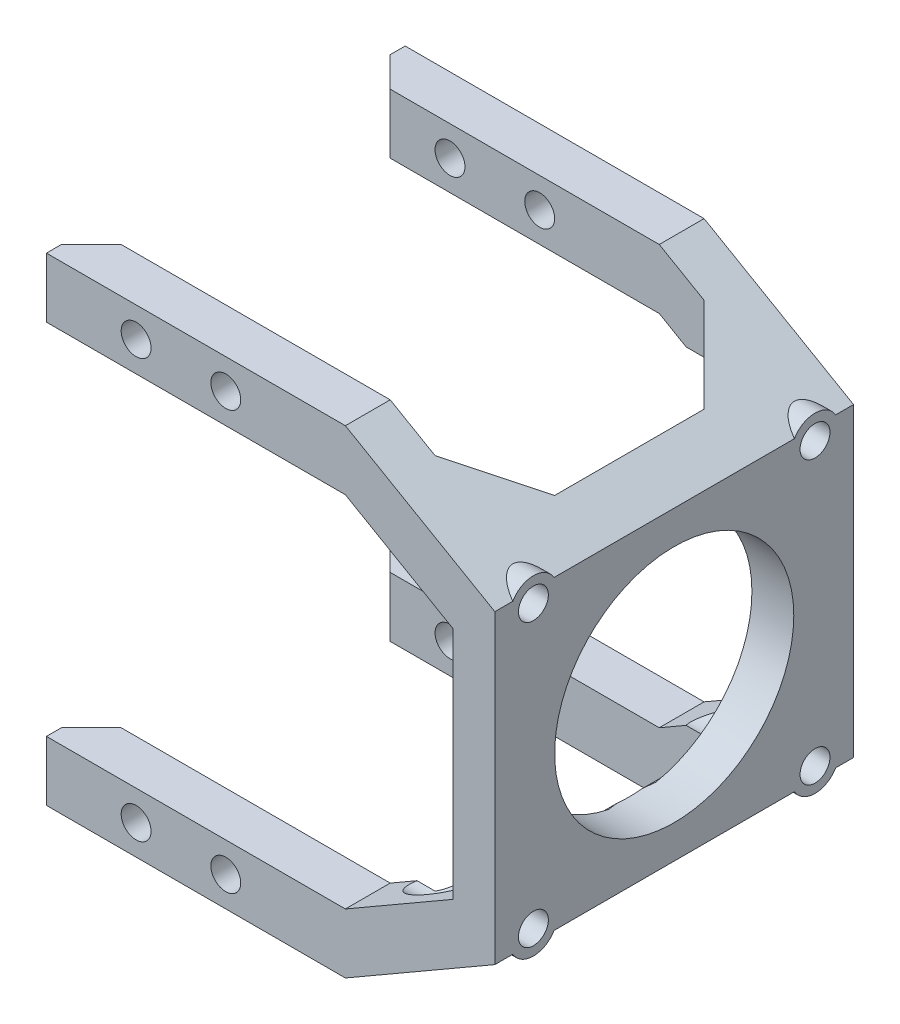
from build123d import *

# Parameters (mm, degrees)
BOSS_EXTRUDE1_DEPTH = 60
SKETCH2_W           = 115
SKETCH2_H           = 45
CUT_EXTRUDE1_DEPTH  = 81
SKETCH3_W           = 7.5
SKETCH3_H           = 10
BOSS_EXTRUDE2_DEPTH = 10
CHAMFER1_SIZE       = 5
SKETCH4_R           = 2.5
CUT_EXTRUDE2_DEPTH  = 61
CHAMFER2_SIZE       = 10
SKETCH5_R           = 20
CUT_EXTRUDE3_DEPTH  = 76
SKETCH6_R           = 2.5
CUT_EXTRUDE4_DEPTH  = 76
SKETCH7_R           = 4
SKETCH7_R_2         = 2.5
BOSS_EXTRUDE3_DEPTH = 5
SKETCH8_R           = 4
CUT_EXTRUDE5_DEPTH  = 69


with BuildPart() as part:
    # Sketch1 → Boss-Extrude1 (new body)
    with BuildSketch(Plane.XY):
        Polygon((0, 0), (25, 14.43375673), (25, 65.56624327), (0, 80), (-40, 80), (-40, 70), (0, 70), (18, 59.607695155), (18, 20.392304845), (0, 10), (-40, 10), (-40, 0), align=None)
    extrude(amount=BOSS_EXTRUDE1_DEPTH)

    # Sketch2 → Cut-Extrude1 (cut, through all)
    with BuildSketch(Plane(origin=(0, 80, 0), x_dir=(1, 0, 0), z_dir=(0, 1, 0))):
        with Locations((-40, -30)):
            Rectangle(SKETCH2_W, SKETCH2_H)
    extrude(amount=-CUT_EXTRUDE1_DEPTH, mode=Mode.SUBTRACT)

    # Sketch3 → Boss-Extrude2 (add)
    with BuildSketch(Plane.ZY.offset(40)):
        with Locations((3.75, 75)):
            Rectangle(SKETCH3_W, SKETCH3_H)
        with Locations((56.25, 75)):
            Rectangle(SKETCH3_W, SKETCH3_H)
        with Locations((56.25, 5)):
            Rectangle(SKETCH3_W, SKETCH3_H)
        with Locations((3.75, 5)):
            Rectangle(SKETCH3_W, SKETCH3_H)
    extrude(amount=BOSS_EXTRUDE2_DEPTH)

    # Chamfer1
    chamfer1_edges = [part.edges().sort_by_distance(p)[0] for p in [
        (-50, 5, 52.5),
        (-50, 5, 7.5),
        (-50, 75, 7.5),
        (-50, 75, 52.5),
    ]]
    chamfer(chamfer1_edges, length=CHAMFER1_SIZE)

    # Sketch4 → Cut-Extrude2 (cut, through all)
    with BuildSketch(Plane(origin=(0, 0, 0), x_dir=(-1, 0, 0), z_dir=(0, 0, -1))):
        with Locations((20, 75)):
            Circle(SKETCH4_R)
        with Locations((35, 75)):
            Circle(SKETCH4_R)
        with Locations((35, 5)):
            Circle(SKETCH4_R)
        with Locations((20, 5)):
            Circle(SKETCH4_R)
    extrude(amount=-CUT_EXTRUDE2_DEPTH, mode=Mode.SUBTRACT)

    # Chamfer2
    chamfer2_edges = [part.edges().sort_by_distance(p)[0] for p in [
        (17.5, 15.103629711, 7.5),
        (17.5, 64.896370289, 7.5),
        (17.5, 15.103629711, 52.5),
        (17.5, 64.896370289, 52.5),
    ]]
    chamfer(chamfer2_edges, length=CHAMFER2_SIZE)

    # Sketch5 → Cut-Extrude3 (cut, through all)
    with BuildSketch(Plane(origin=(25, 0, 0), x_dir=(0, 0, -1), z_dir=(1, 0, 0))):
        with Locations((-30, 40)):
            Circle(SKETCH5_R)
    extrude(amount=-CUT_EXTRUDE3_DEPTH, mode=Mode.SUBTRACT)

    # Sketch6 → Cut-Extrude4 (cut, through all)
    with BuildSketch(Plane(origin=(25, 0, 0), x_dir=(0, 0, -1), z_dir=(1, 0, 0))):
        with Locations((-53.55, 63.55)):
            Circle(SKETCH6_R)
        with Locations((-6.45, 63.55)):
            Circle(SKETCH6_R)
        with Locations((-6.45, 16.45)):
            Circle(SKETCH6_R)
        with Locations((-53.55, 16.45)):
            Circle(SKETCH6_R)
    extrude(amount=-CUT_EXTRUDE4_DEPTH, mode=Mode.SUBTRACT)

    # Sketch7 → Boss-Extrude3 (add)
    with BuildSketch(Plane(origin=(25, 0, 0), x_dir=(0, 0, -1), z_dir=(1, 0, 0))):
        with Locations((-53.55, 63.55)):
            Circle(SKETCH7_R)
        with Locations((-53.55, 63.55)):
            Circle(SKETCH7_R_2, mode=Mode.SUBTRACT)
        with Locations((-6.45, 63.55)):
            Circle(SKETCH7_R)
        with Locations((-6.45, 63.55)):
            Circle(SKETCH7_R_2, mode=Mode.SUBTRACT)
        with Locations((-6.45, 16.45)):
            Circle(SKETCH7_R)
        with Locations((-6.45, 16.45)):
            Circle(SKETCH7_R_2, mode=Mode.SUBTRACT)
        with Locations((-53.55, 16.45)):
            Circle(SKETCH7_R)
        with Locations((-53.55, 16.45)):
            Circle(SKETCH7_R_2, mode=Mode.SUBTRACT)
    extrude(amount=-BOSS_EXTRUDE3_DEPTH)

    # Sketch8 → Cut-Extrude5 (cut, through all)
    with BuildSketch(Plane.ZY.offset(-18)):
        with Locations((6.45, 63.55)):
            Circle(SKETCH8_R)
        with Locations((53.55, 63.55)):
            Circle(SKETCH8_R)
        with Locations((53.55, 16.45)):
            Circle(SKETCH8_R)
        with Locations((6.45, 16.45)):
            Circle(SKETCH8_R)
    extrude(amount=CUT_EXTRUDE5_DEPTH, mode=Mode.SUBTRACT)


solid = part.part
